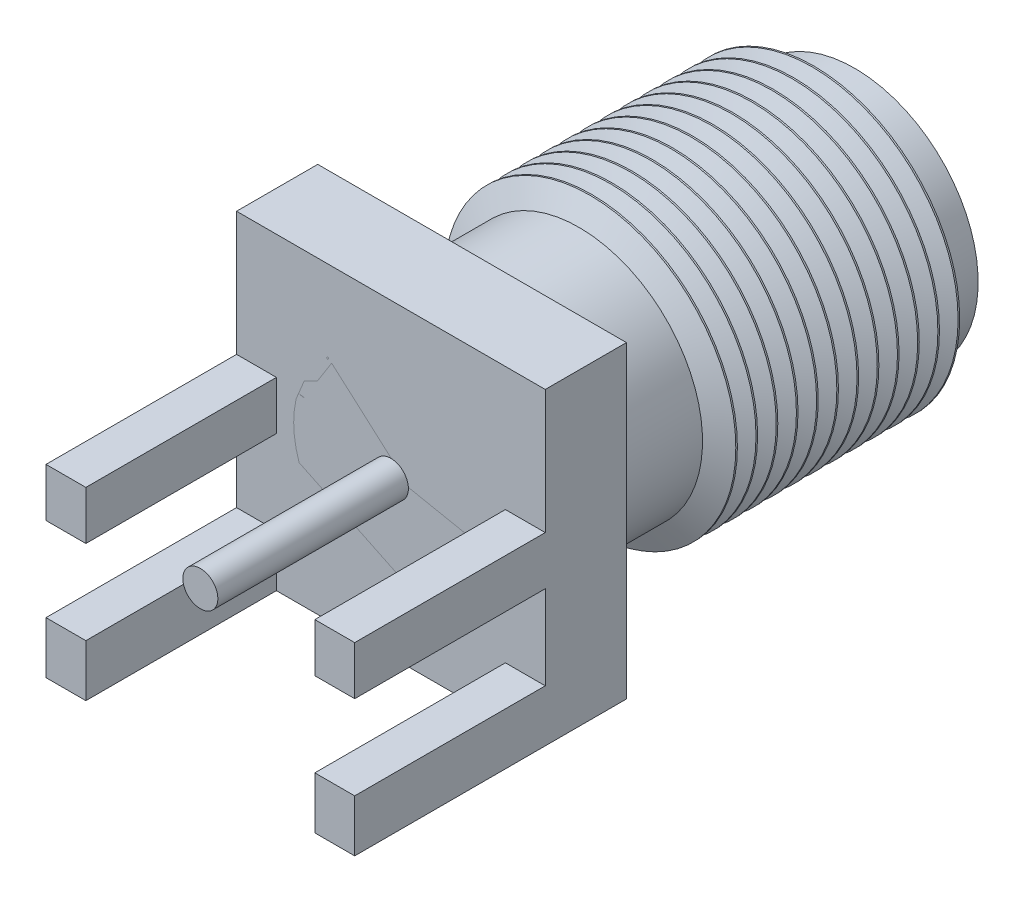
from build123d import *

# Parameters (mm, degrees)
SKETCH1_W           = 6.35
SKETCH1_H           = 1.67
BOSS_EXTRUDE1_DEPTH = 6.35
SKETCH2_R           = 0.36
SKETCH2_W           = 0.82
SKETCH2_H           = 1.07
SKETCH2_H_2         = 1
BOSS_EXTRUDE2_DEPTH = 3.92
SKETCH3_R           = 2
BOSS_EXTRUDE3_DEPTH = 7.5
SKETCH4_R           = 3
BOSS_EXTRUDE4_DEPTH = 7.87
SKETCH5_R           = 2.1
CUT_EXTRUDE1_DEPTH  = 2.16
BOSS_EXTRUDE5_START = -11.43
SKETCH6_R           = 0.36
BOSS_EXTRUDE5_DEPTH = 11.43


with BuildPart() as part:
    # Sketch1 → Boss-Extrude1 (new body)
    with BuildSketch(Plane(origin=(0, 0, 0), x_dir=(1, 0, 0), z_dir=(0, 1, 0))):
        with Locations((3.175, 0.835)):
            Rectangle(SKETCH1_W, SKETCH1_H)
    extrude(amount=BOSS_EXTRUDE1_DEPTH)

    # Sketch2 → Boss-Extrude2 (add)
    with BuildSketch(Plane.XY):
        with Locations((3.175, 3.175)):
            Circle(SKETCH2_R)
        with Locations((0.41, 0.535)):
            Rectangle(SKETCH2_W, SKETCH2_H)
        with Locations((5.94, 0.535)):
            Rectangle(SKETCH2_W, SKETCH2_H)
        with Locations((0.41, 3.3)):
            Rectangle(SKETCH2_W, SKETCH2_H_2)
        with Locations((5.94, 3.3)):
            Rectangle(SKETCH2_W, SKETCH2_H_2)
    extrude(amount=BOSS_EXTRUDE2_DEPTH)

    # Sketch4 → Boss-Extrude4 (add)
    with BuildSketch(Plane(origin=(0, 0, -1.67), x_dir=(-1, 0, 0), z_dir=(0, 0, -1))):
        with Locations((-3.175, 3.175)):
            Circle(SKETCH4_R)
    extrude(amount=BOSS_EXTRUDE4_DEPTH)

    # Sketch5 → Cut-Extrude1 (cut)
    with BuildSketch(Plane(origin=(0, 0, -9.54), x_dir=(-1, 0, 0), z_dir=(0, 0, -1))):
        with Locations((-3.175, 3.175)):
            Circle(SKETCH5_R)
    extrude(amount=-CUT_EXTRUDE1_DEPTH, mode=Mode.SUBTRACT)

    # Sketch6 → Boss-Extrude5 (add)
    with BuildSketch(Plane.XY.offset(3.92).offset(BOSS_EXTRUDE5_START)):
        with Locations((3.175, 3.175)):
            Circle(SKETCH6_R)
    extrude(amount=BOSS_EXTRUDE5_DEPTH)

    # Sketch7 → Cut-Revolve1 (revolve, cut)
    with BuildSketch(Plane(origin=(3.175, 0, 0), x_dir=(0, 0, -1), z_dir=(1, 0, 0))):
        Polygon((1.67, 6.35), (1.67, 5.715), (3.870089104, 5.715), (4.114006287, 6.214558359), (4.285777487, 5.715), (4.52969467, 6.214558359), (4.701465871, 5.715), (4.945383054, 6.214558359), (5.117154254, 5.715), (5.361071437, 6.214558359), (5.532842638, 5.715), (5.776759821, 6.214558359), (5.948531021, 5.715), (6.192448204, 6.214558359), (6.364219405, 5.715), (6.608136588, 6.214558359), (6.779907788, 5.715), (7.023824971, 6.214558359), (7.195596172, 5.715), (7.439513355, 6.214558359), (7.611284555, 5.715), (7.855201738, 6.214558359), (8.026972939, 5.715), (8.270890122, 6.214558359), (8.442661322, 5.715), (8.686578505, 6.214558359), (8.858349706, 5.715), (9.54, 5.715), (9.54, 6.35), align=None)
    revolve(axis=Axis((3.175, 3.175, -9.54), (0, 0, 1)), mode=Mode.SUBTRACT)


with BuildPart() as body_2:
    # Sketch3 → Boss-Extrude3 (new body)
    with BuildSketch(Plane.XY):
        with Locations((3.175, 3.175)):
            Circle(SKETCH3_R)
    extrude(amount=-BOSS_EXTRUDE3_DEPTH)


solid = Compound([part.part, body_2.part])
